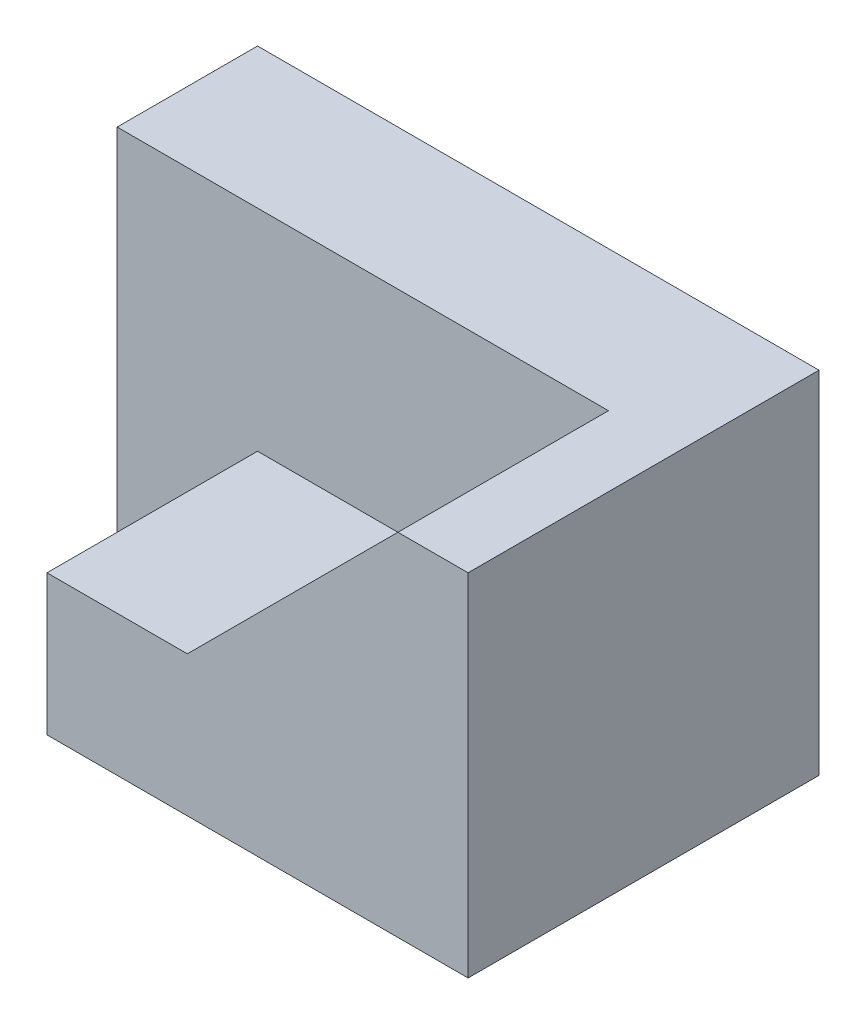
from build123d import *

# Parameters (mm, degrees)
SKETCH1_W           = 80
SKETCH1_H           = 50
BOSS_EXTRUDE1_DEPTH = 50
CUT_EXTRUDE1_DEPTH  = 30


with BuildPart() as part:
    # Sketch1 → Boss-Extrude1 (new body)
    with BuildSketch(Plane.XY):
        with Locations((40, 25)):
            Rectangle(SKETCH1_W, SKETCH1_H)
    extrude(amount=BOSS_EXTRUDE1_DEPTH)

    # Sketch2 → Cut-Extrude1 (cut)
    with BuildSketch(Plane.XY.offset(50)):
        Polygon((20, 0), (0, 0), (0, 50), (70, 50), (40, 20), (20, 20), align=None)
    extrude(amount=-CUT_EXTRUDE1_DEPTH, mode=Mode.SUBTRACT)


solid = part.part
